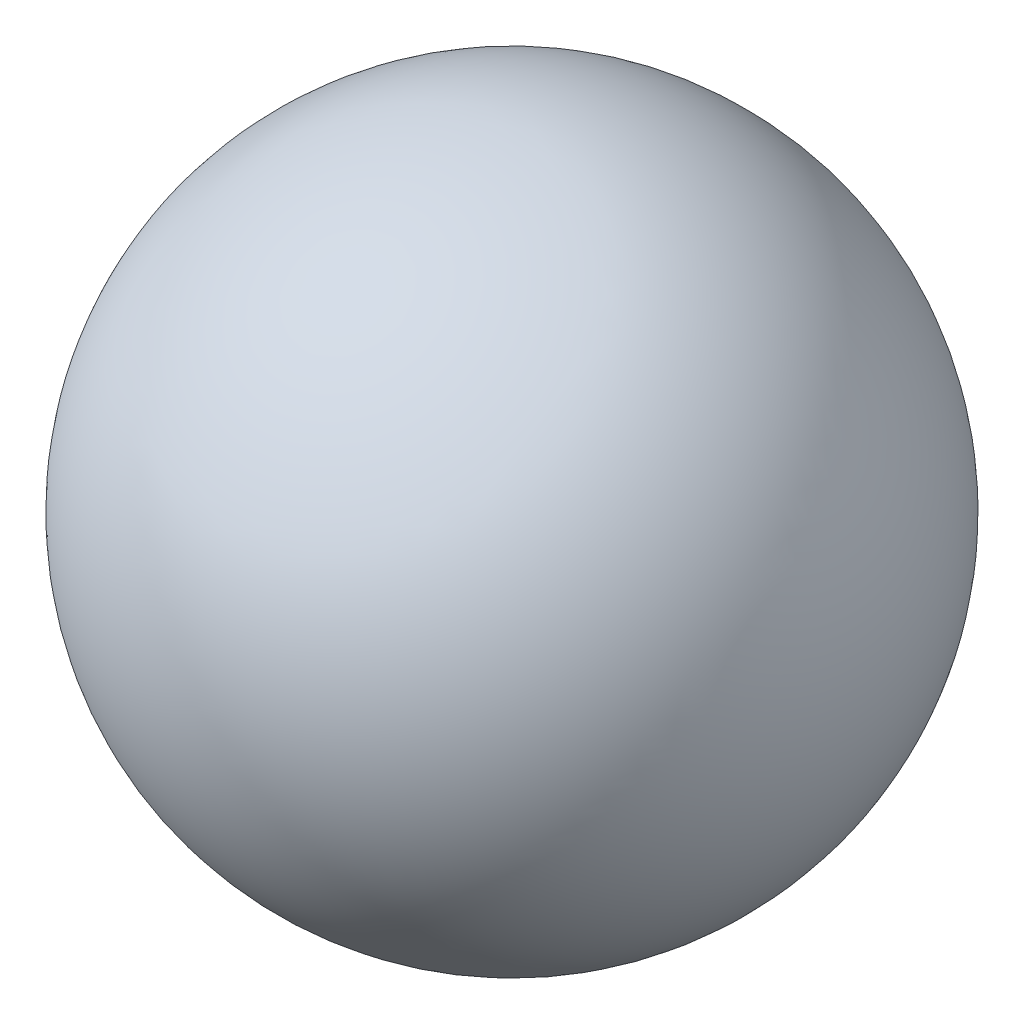
from build123d import *


with BuildPart() as part:
    # Sketch2 → Revolve1 (revolve)
    with BuildSketch(Plane.XY):
        with BuildLine():
            Line((-127, 0), (127, 0))
            ThreePointArc((127, 0), (0, 127), (-127, 0))
        make_face()
    revolve(axis=Axis((-127, 0, 0), (1, 0, 0)))


solid = part.part
